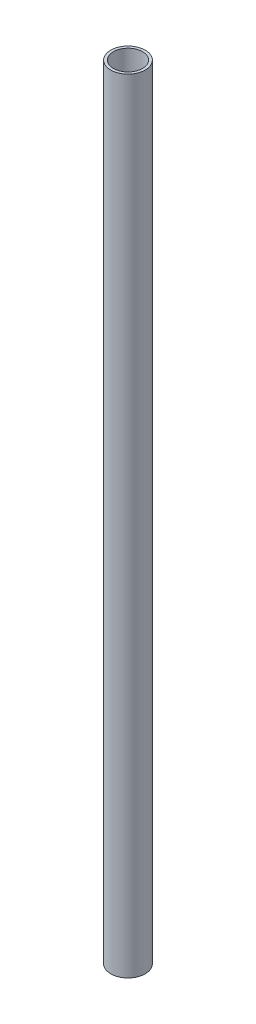
from build123d import *

# Parameters (mm, degrees)
SKETCH_1_R      = 13
SKETCH_1_R_2    = 11
EXTRUDE_1_DEPTH = 590


with BuildPart() as part:
    # 草图1 → 凸台-拉伸1 (new body)
    with BuildSketch(Plane(origin=(0, 0, 0), x_dir=(1, 0, 0), z_dir=(0, 1, 0))):
        Circle(SKETCH_1_R)
        Circle(SKETCH_1_R_2, mode=Mode.SUBTRACT)
    extrude(amount=EXTRUDE_1_DEPTH)


solid = part.part
